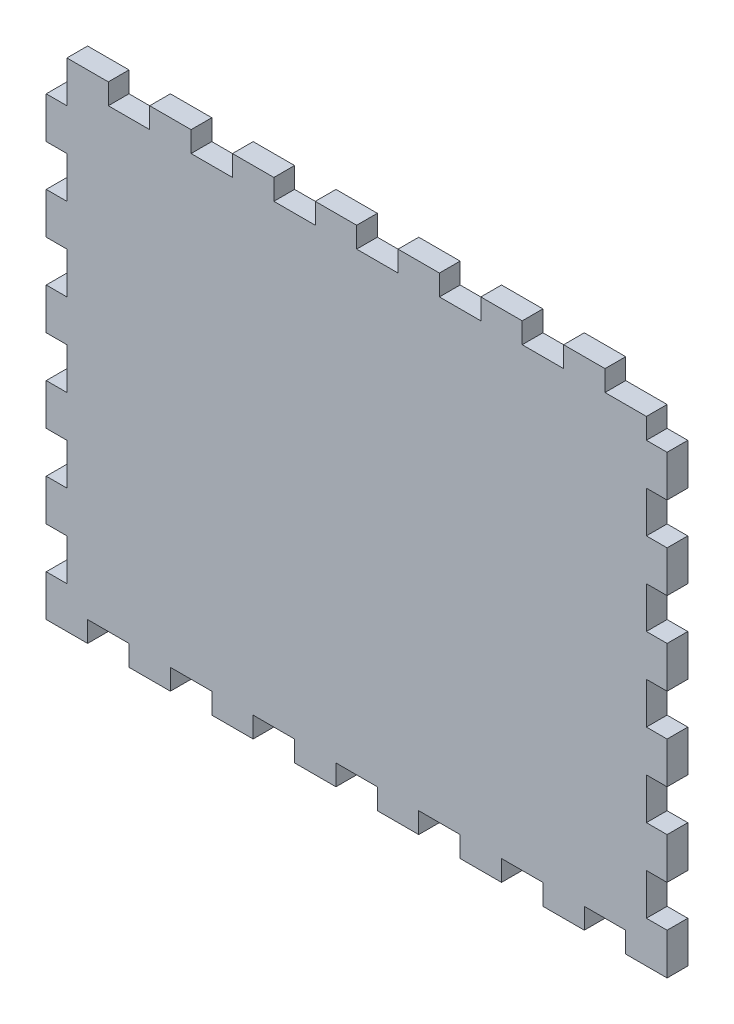
from build123d import *

# Parameters (mm, degrees)
SKETCH1_W               = 190.5
SKETCH1_H               = 152.4
BOSS_EXTRUDE1_DEPTH     = 6.35
SKETCH2_W               = 12.7
SKETCH2_H               = 6.35
CUT_EXTRUDE1_DEPTH      = 7.35
LPATTERN1_COUNT         = 7
LPATTERN1_PITCH         = 25.4
SKETCH3_W               = 6.35
SKETCH3_H               = 12.7
CUT_EXTRUDE2_DEPTH      = 7.35
LPATTERN2_COUNT         = 6
LPATTERN2_PITCH         = 25.4
MIRROR2_COPY_1_SKETCH_W = 6.35
MIRROR2_COPY_1_SKETCH_H = 12.7
MIRROR2_COPY_1_DEPTH    = 7.35
MIRROR2_COPY_2_SKETCH_W = 6.35
MIRROR2_COPY_2_SKETCH_H = 12.7
MIRROR2_COPY_2_DEPTH    = 7.35
MIRROR2_COPY_3_SKETCH_W = 6.35
MIRROR2_COPY_3_SKETCH_H = 12.7
MIRROR2_COPY_3_DEPTH    = 7.35
MIRROR2_COPY_4_SKETCH_W = 6.35
MIRROR2_COPY_4_SKETCH_H = 12.7
MIRROR2_COPY_4_DEPTH    = 7.35
MIRROR2_COPY_5_SKETCH_W = 6.35
MIRROR2_COPY_5_SKETCH_H = 12.7
MIRROR2_COPY_5_DEPTH    = 7.35
SKETCH4_W               = 12.7
SKETCH4_H               = 6.35
CUT_EXTRUDE3_DEPTH      = 7.35
LPATTERN3_COUNT         = 7
LPATTERN3_PITCH         = 25.4


with BuildPart() as part:
    # Sketch1 → Boss-Extrude1 (new body)
    with BuildSketch(Plane.XY):
        Rectangle(SKETCH1_W, SKETCH1_H)
    extrude(amount=BOSS_EXTRUDE1_DEPTH)

    # Sketch2 → Cut-Extrude1 (cut, through all)
    with BuildSketch(Plane.XY.offset(6.35)):
        with Locations((-69.85, 73.025)):
            Rectangle(SKETCH2_W, SKETCH2_H)
    cut_extrude1 = extrude(amount=-CUT_EXTRUDE1_DEPTH, mode=Mode.SUBTRACT)

    # LPattern1: Cut-Extrude1 ×7
    with Locations(*[(i * LPATTERN1_PITCH, 0, 0) for i in range(1, LPATTERN1_COUNT)]):
        add(cut_extrude1, mode=Mode.SUBTRACT)

    # Sketch3 → Cut-Extrude2 (cut, through all)
    with BuildSketch(Plane.XY.offset(6.35)):
        with Locations((92.075, 69.85)):
            Rectangle(SKETCH3_W, SKETCH3_H)
    cut_extrude2 = extrude(amount=-CUT_EXTRUDE2_DEPTH, mode=Mode.SUBTRACT)

    # LPattern2: Cut-Extrude2 ×6
    with Locations(*[(0, -i * LPATTERN2_PITCH, 0) for i in range(1, LPATTERN2_COUNT)]):
        add(cut_extrude2, mode=Mode.SUBTRACT)

    # Mirror2: Cut-Extrude2 across plane
    add(cut_extrude2.mirror(Plane(origin=(0, 0, 0), x_dir=(0, 0, 1), z_dir=(1, 0, 0))), mode=Mode.SUBTRACT)

    # Mirror2 copy 1 sketch → Mirror2 copy 1 (cut, through all)
    with BuildSketch(Plane(origin=(0, -25.4, 6.35), x_dir=(-1, 0, 0), z_dir=(0, 0, 1))):
        with Locations((92.075, -69.85)):
            Rectangle(MIRROR2_COPY_1_SKETCH_W, MIRROR2_COPY_1_SKETCH_H)
    extrude(amount=-MIRROR2_COPY_1_DEPTH, mode=Mode.SUBTRACT)

    # Mirror2 copy 2 sketch → Mirror2 copy 2 (cut, through all)
    with BuildSketch(Plane(origin=(0, -50.8, 6.35), x_dir=(-1, 0, 0), z_dir=(0, 0, 1))):
        with Locations((92.075, -69.85)):
            Rectangle(MIRROR2_COPY_2_SKETCH_W, MIRROR2_COPY_2_SKETCH_H)
    extrude(amount=-MIRROR2_COPY_2_DEPTH, mode=Mode.SUBTRACT)

    # Mirror2 copy 3 sketch → Mirror2 copy 3 (cut, through all)
    with BuildSketch(Plane(origin=(0, -76.2, 6.35), x_dir=(-1, 0, 0), z_dir=(0, 0, 1))):
        with Locations((92.075, -69.85)):
            Rectangle(MIRROR2_COPY_3_SKETCH_W, MIRROR2_COPY_3_SKETCH_H)
    extrude(amount=-MIRROR2_COPY_3_DEPTH, mode=Mode.SUBTRACT)

    # Mirror2 copy 4 sketch → Mirror2 copy 4 (cut, through all)
    with BuildSketch(Plane(origin=(0, -101.6, 6.35), x_dir=(-1, 0, 0), z_dir=(0, 0, 1))):
        with Locations((92.075, -69.85)):
            Rectangle(MIRROR2_COPY_4_SKETCH_W, MIRROR2_COPY_4_SKETCH_H)
    extrude(amount=-MIRROR2_COPY_4_DEPTH, mode=Mode.SUBTRACT)

    # Mirror2 copy 5 sketch → Mirror2 copy 5 (cut, through all)
    with BuildSketch(Plane(origin=(0, -127, 6.35), x_dir=(-1, 0, 0), z_dir=(0, 0, 1))):
        with Locations((92.075, -69.85)):
            Rectangle(MIRROR2_COPY_5_SKETCH_W, MIRROR2_COPY_5_SKETCH_H)
    extrude(amount=-MIRROR2_COPY_5_DEPTH, mode=Mode.SUBTRACT)

    # Sketch4 → Cut-Extrude3 (cut, through all)
    with BuildSketch(Plane.XY.offset(6.35)):
        with Locations((-76.2, -73.025)):
            Rectangle(SKETCH4_W, SKETCH4_H)
    cut_extrude3 = extrude(amount=-CUT_EXTRUDE3_DEPTH, mode=Mode.SUBTRACT)

    # LPattern3: Cut-Extrude3 ×7
    with Locations(*[(i * LPATTERN3_PITCH, 0, 0) for i in range(1, LPATTERN3_COUNT)]):
        add(cut_extrude3, mode=Mode.SUBTRACT)


solid = part.part
